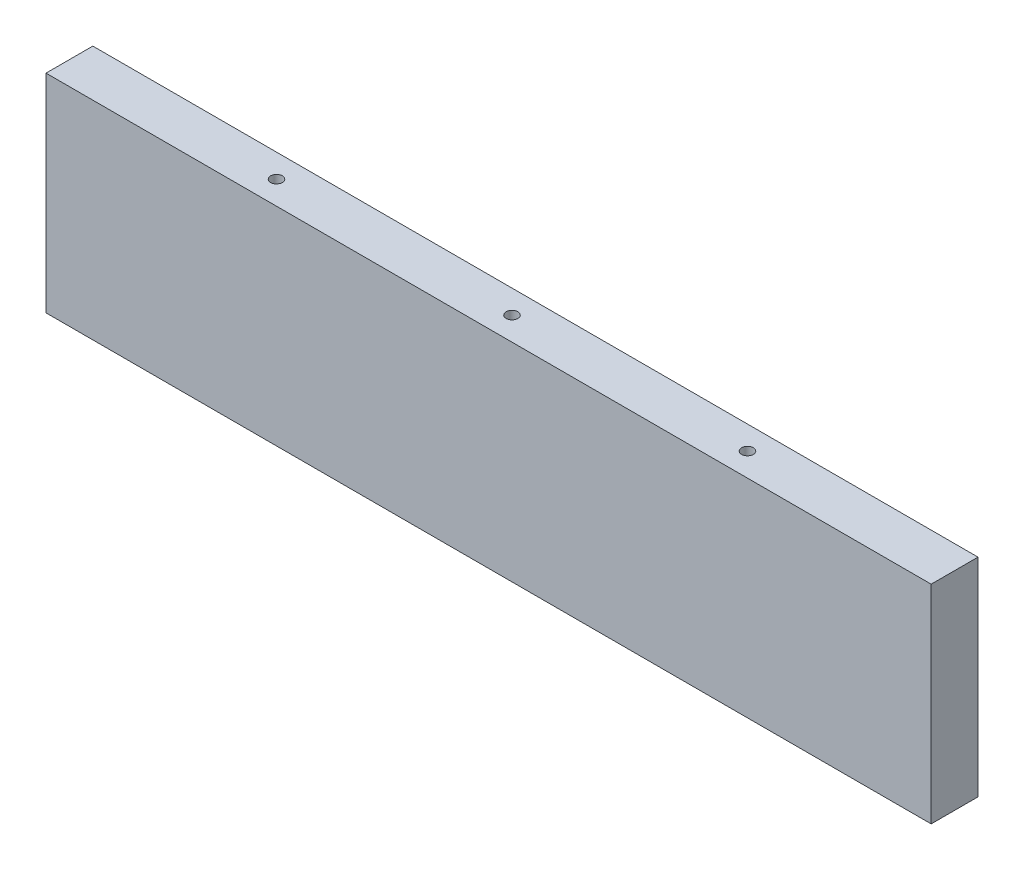
from build123d import *

# Parameters (mm, degrees)
SKETCH1_W           = 214.599999988
SKETCH1_H           = 56.3
BOSS_EXTRUDE1_DEPTH = 12.7
SKETCH3_W           = 12.7
SKETCH3_H           = 56.3
BOSS_EXTRUDE2_DEPTH = 12.7
SKETCH4_W           = 12.7
SKETCH4_H           = 56.3
BOSS_EXTRUDE3_DEPTH = 12.7
HOLE1_D             = 3.175
HOLE1_DEPTH         = 31.75
HOLE1_CSINK_D       = 10.16
HOLE1_CSINK_ANGLE   = 82
HOLE1_TIP           = 0.953866233
HOLE2_D             = 3.175
HOLE2_DEPTH         = 31.75
HOLE2_CSINK_D       = 10.16
HOLE2_CSINK_ANGLE   = 82
HOLE2_TIP           = 0.953866233


with BuildPart() as part:
    # Sketch1 → Boss-Extrude1 (new body)
    with BuildSketch(Plane.XY):
        with Locations((-124.004465969, 40.85)):
            Rectangle(SKETCH1_W, SKETCH1_H)
    extrude(amount=-BOSS_EXTRUDE1_DEPTH)

    # Sketch3 → Boss-Extrude2 (add)
    with BuildSketch(Plane.ZY.offset(231.304465963)):
        with Locations((-6.35, 40.85)):
            Rectangle(SKETCH3_W, SKETCH3_H)
    extrude(amount=BOSS_EXTRUDE2_DEPTH)

    # Sketch4 → Boss-Extrude3 (add)
    with BuildSketch(Plane(origin=(-16.704465975, 0, 0), x_dir=(0, 0, -1), z_dir=(1, 0, 0))):
        with Locations((6.35, 40.85)):
            Rectangle(SKETCH4_W, SKETCH4_H)
    extrude(amount=BOSS_EXTRUDE3_DEPTH)

    # Hole1
    with Locations(Plane(origin=(-124.004465969, 0, 155.024290059), x_dir=(-1, 0, 0), z_dir=(0, -1, 0))):
        with Locations((113.649999994, 128.807623392), (113.649999994, 23.940956725), (-94.599999994, 161.374290059), (94.599999994, 161.374290059), (0, 161.374290059), (0, 193.124290059), (0, 440.553783621), (0, 301.970350905), (40.979166666, 301.970350905), (166.795833328, 301.970350905), (207.774999994, 440.553783621), (207.774999994, 333.02141023), (207.774999994, 225.48903684), (207.774999994, 137.424290059), (207.774999994, 10.424290059), (-207.774999994, 10.424290059), (-207.774999994, 137.424290059), (-207.774999994, 225.48903684), (-207.774999994, 333.02141023), (-207.774999994, 440.553783621), (-166.795833328, 301.970350905), (-40.979166666, 301.970350905), (-113.649999994, 23.940956725), (-113.649999994, 128.807623392)):
            CounterSinkHole(HOLE1_D / 2, HOLE1_CSINK_D / 2, depth=HOLE1_DEPTH, counter_sink_angle=HOLE1_CSINK_ANGLE)
            with Locations((0, 0, -(HOLE1_DEPTH + HOLE1_TIP / 2))):  # 118° drill point
                Cone(0, HOLE1_D / 2, HOLE1_TIP, mode=Mode.SUBTRACT)

    # Hole2
    with Locations(Plane(origin=(-124.004465969, 88.05, 155.024290059), x_dir=(1, 0, 0), z_dir=(0, 1, 0))):
        with Locations((-162.299999994, -8.625709941), (-113.649999994, 50.157623392), (-113.649999994, 102.590956725), (162.299999994, -8.625709941), (113.649999994, 50.157623392), (113.649999994, 102.590956725), (63.85, 161.374290059), (0, 161.374290059), (-63.85, 161.374290059)):
            CounterSinkHole(HOLE2_D / 2, HOLE2_CSINK_D / 2, depth=HOLE2_DEPTH, counter_sink_angle=HOLE2_CSINK_ANGLE)
            with Locations((0, 0, -(HOLE2_DEPTH + HOLE2_TIP / 2))):  # 118° drill point
                Cone(0, HOLE2_D / 2, HOLE2_TIP, mode=Mode.SUBTRACT)


solid = part.part
